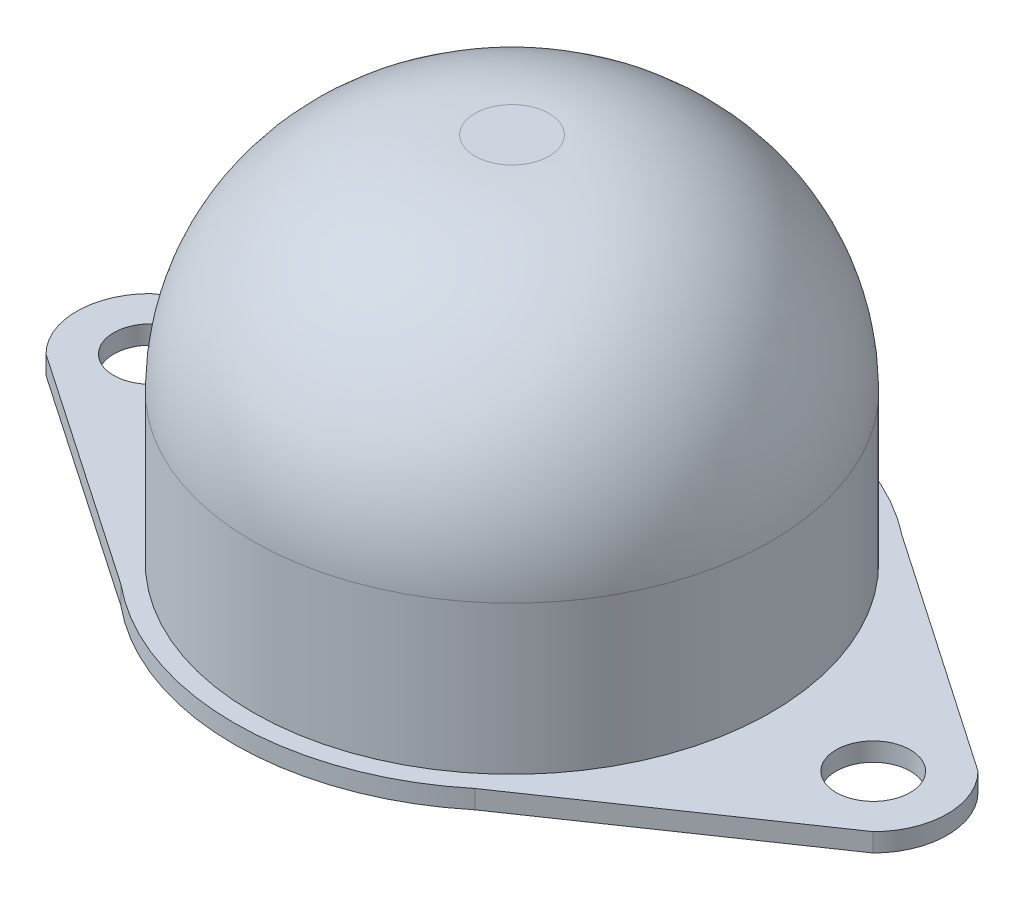
from build123d import *

# Parameters (mm, degrees)
SKETCH1_R           = 14
BOSS_EXTRUDE1_DEPTH = 20
FILLET_1_R          = 12
SKETCH2_R           = 15
BOSS_EXTRUDE2_DEPTH = 1
SKETCH3_R           = 2
BOSS_EXTRUDE3_DEPTH = 1


with BuildPart() as part:
    # Sketch1 → Boss-Extrude1 (new body)
    with BuildSketch(Plane(origin=(0, 0, 0), x_dir=(1, 0, 0), z_dir=(0, 1, 0))):
        Circle(SKETCH1_R)
    extrude(amount=BOSS_EXTRUDE1_DEPTH)

    # Fillet 1
    fillet_1_edges = [part.edges().sort_by_distance(p)[0] for p in [
        (-14, 20, 0),
    ]]
    fillet(fillet_1_edges, radius=FILLET_1_R)

    # Sketch2 → Boss-Extrude2 (add)
    with BuildSketch(Plane(origin=(0, 0, 0), x_dir=(-1, 0, 0), z_dir=(0, -1, 0))):
        Circle(SKETCH2_R)
    extrude(amount=BOSS_EXTRUDE2_DEPTH)

    # Sketch3 → Boss-Extrude3 (add)
    with BuildSketch(Plane(origin=(0, 0, 0), x_dir=(1, 0, 0), z_dir=(0, 1, 0))):
        with BuildLine():
            Line((-9.300297681, 11.768791911), (-22.328427125, 2.828427125))
            ThreePointArc((-22.328427125, 2.828427125), (-23.19551813, 1.530733729), (-23.5, 0))
            ThreePointArc((-23.5, 0), (-23.19551813, -1.530733729), (-22.328427125, -2.828427125))
            Line((-22.328427125, -2.828427125), (-9.556823766, -11.561449714))
            ThreePointArc((-9.556823766, -11.561449714), (-14.999093336, 0.164921511), (-9.300297681, 11.768791911))
        make_face()
        with Locations((-19.5, 0)):
            Circle(SKETCH3_R, mode=Mode.SUBTRACT)
        with BuildLine():
            Line((22.328427125, 2.828427125), (9.300297681, 11.768791911))
            ThreePointArc((9.300297681, 11.768791911), (13.500082689, 6.538177681), (15, 0))
            ThreePointArc((15, 0), (13.571152429, -6.389352217), (9.556823766, -11.561449714))
            Line((9.556823766, -11.561449714), (22.328427125, -2.828427125))
            ThreePointArc((22.328427125, -2.828427125), (23.19551813, -1.530733729), (23.5, 0))
            ThreePointArc((23.5, 0), (23.19551813, 1.530733729), (22.328427125, 2.828427125))
        make_face()
        with Locations((19.5, 0)):
            Circle(SKETCH3_R, mode=Mode.SUBTRACT)
    extrude(amount=-BOSS_EXTRUDE3_DEPTH)


solid = part.part
